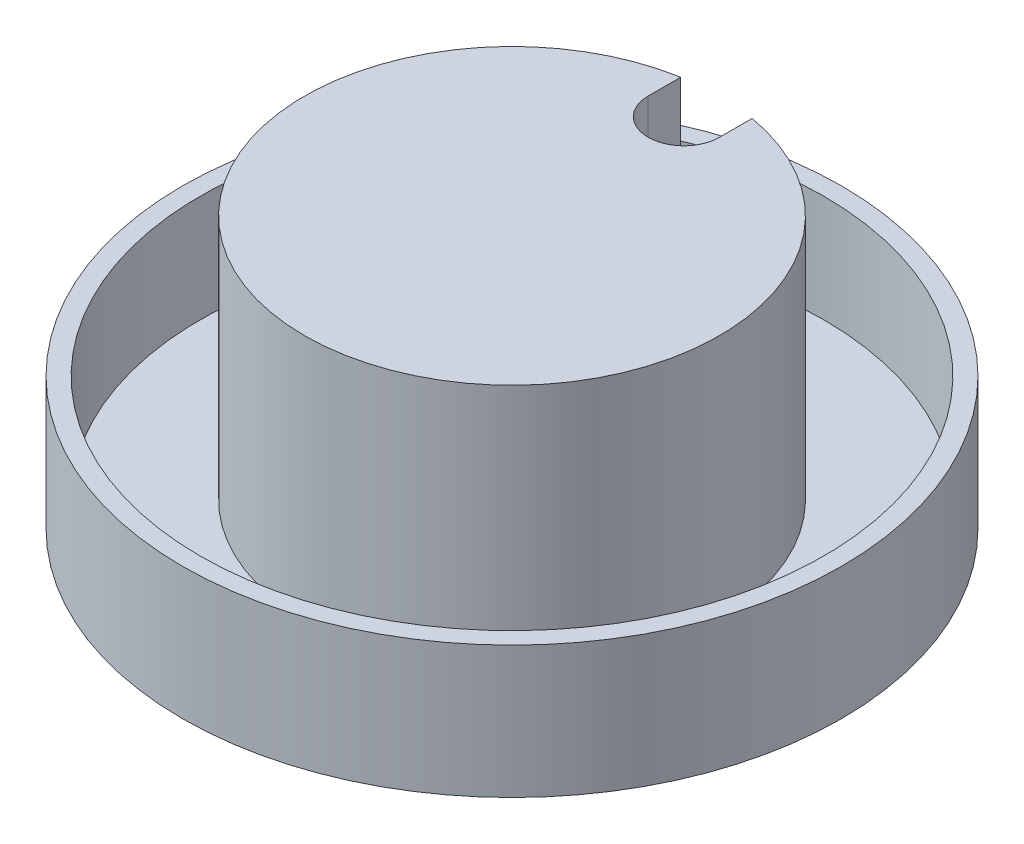
from build123d import *

# Parameters (mm, degrees)
SKETCH1_R            = 19.85
SKETCH1_R_2          = 18.78
BOSS_EXTRUDE3_DEPTH  = 7.95
SKETCH2_R            = 18.78
BOSS_EXTRUDE5_DEPTH  = 1.5
SKETCH4_R            = 12.5
BOSS_EXTRUDE6_DEPTH  = 16.31
SKETCH5_R            = 2.15
SKETCH5_W            = 4.3
SKETCH5_H            = 2.15
CUT_EXTRUDE2_DEPTH   = 16.31
SKETCH6_R            = 11.597360911
CUT_EXTRUDE3_DEPTH   = 14.809999892
SKETCH12_R           = 3.4
SKETCH12_W           = 6.8
SKETCH12_H           = 3.4
BOSS_EXTRUDE8_DEPTH  = 24.969999892
SKETCH5_6_R          = 2.15
SKETCH5_6_W          = 4.3
SKETCH5_6_H          = 2.15
CUT_EXTRUDE5_DEPTH   = 24.969999892
CUT_EXTRUDE6_START   = -14.81
SKETCH14_R           = 15.219310499
SKETCH14_R_2         = 12.5
CUT_EXTRUDE6_DEPTH   = 14.81
SKETCH17_W           = 6.8
SKETCH17_H           = 2.662223843
CUT_EXTRUDE7_DEPTH   = 16.587999892
SKETCH18_R           = 3.4
SKETCH18_R_2         = 2.15
BOSS_EXTRUDE10_DEPTH = 14
SKETCH19_R           = 5.618160511
SKETCH19_R_2         = 3.4
CUT_EXTRUDE8_DEPTH   = 14


with BuildPart() as part:
    # Sketch1 → Boss-Extrude3 (new body)
    with BuildSketch(Plane(origin=(0, 0, 0), x_dir=(1, 0, 0), z_dir=(0, 1, 0))):
        Circle(SKETCH1_R)
        Circle(SKETCH1_R_2, mode=Mode.SUBTRACT)
    extrude(amount=BOSS_EXTRUDE3_DEPTH)

    # Sketch2 → Boss-Extrude5 (add)
    with BuildSketch(Plane.XZ):
        Circle(SKETCH2_R)
    extrude(amount=-BOSS_EXTRUDE5_DEPTH)


with BuildPart() as body_2:
    # Sketch4 → Boss-Extrude6 (new body)
    with BuildSketch(Plane.XZ):
        Circle(SKETCH4_R)
    extrude(amount=-BOSS_EXTRUDE6_DEPTH)


with BuildPart() as cut_extrude2_tool:
    # Sketch5 → Cut-Extrude2 (new body)
    with BuildSketch(Plane(origin=(0, 16.31, 0), x_dir=(1, 0, 0), z_dir=(0, 1, 0))):
        with Locations((0, 10.35)):
            Circle(SKETCH5_R)
        with Locations((0, 11.425)):
            Rectangle(SKETCH5_W, SKETCH5_H)
    extrude(amount=-CUT_EXTRUDE2_DEPTH)


with BuildPart() as part_1:
    add(part.part)

    # Cut-Extrude2: cut by cut_extrude2_tool
    add(cut_extrude2_tool.part, mode=Mode.SUBTRACT)


with BuildPart() as body_2_1:
    add(body_2.part)

    # Cut-Extrude2: cut by cut_extrude2_tool
    add(cut_extrude2_tool.part, mode=Mode.SUBTRACT)


with BuildPart() as cut_extrude3_tool:
    # Sketch6 → Cut-Extrude3 (new body)
    with BuildSketch(Plane.XZ):
        Circle(SKETCH6_R)
    extrude(amount=-CUT_EXTRUDE3_DEPTH)


with BuildPart() as part_2:
    add(part_1.part)

    # Cut-Extrude3: cut by cut_extrude3_tool
    add(cut_extrude3_tool.part, mode=Mode.SUBTRACT)



with BuildPart() as body_2_2:
    add(body_2_1.part)

    # Cut-Extrude3: cut by cut_extrude3_tool
    add(cut_extrude3_tool.part, mode=Mode.SUBTRACT)


with BuildPart() as part_3:
    add(part_2.part)

    add(body_2_2.part)  # Boss-Extrude8 merges body 2
    # Sketch12 → Boss-Extrude8 (add)
    with BuildSketch(Plane(origin=(0, 16.31, 0), x_dir=(1, 0, 0), z_dir=(0, 1, 0))):
        with Locations((0, 10.35)):
            Circle(SKETCH12_R)
        with Locations((0, 12.05)):
            Rectangle(SKETCH12_W, SKETCH12_H)
    extrude(amount=-BOSS_EXTRUDE8_DEPTH)

    # Sketch5_6 → Cut-Extrude5 (cut)
    with BuildSketch(Plane(origin=(0, 16.31, 0), x_dir=(1, 0, 0), z_dir=(0, 1, 0))):
        with Locations((0, 10.35)):
            Circle(SKETCH5_6_R)
        with Locations((0, 11.425)):
            Rectangle(SKETCH5_6_W, SKETCH5_6_H)
    extrude(amount=-CUT_EXTRUDE5_DEPTH, mode=Mode.SUBTRACT)

    # Sketch14 → Cut-Extrude6 (cut)
    with BuildSketch(Plane(origin=(0, 16.31, 0), x_dir=(1, 0, 0), z_dir=(0, 1, 0)).offset(CUT_EXTRUDE6_START)):
        Circle(SKETCH14_R)
        Circle(SKETCH14_R_2, mode=Mode.SUBTRACT)
    extrude(amount=CUT_EXTRUDE6_DEPTH, mode=Mode.SUBTRACT)

    # Sketch17 → Cut-Extrude7 (cut)
    with BuildSketch(Plane.XZ):
        with Locations((0, -12.418888079)):
            Rectangle(SKETCH17_W, SKETCH17_H)
    extrude(amount=CUT_EXTRUDE7_DEPTH, mode=Mode.SUBTRACT)

    # Sketch18 → Boss-Extrude10 (add)
    with BuildSketch(Plane.XZ):
        with Locations((0, -10.35)):
            Circle(SKETCH18_R)
        with Locations((0, -10.35)):
            Circle(SKETCH18_R_2, mode=Mode.SUBTRACT)
    extrude(amount=BOSS_EXTRUDE10_DEPTH)

    # Sketch19 → Cut-Extrude8 (cut)
    with BuildSketch(Plane.XZ):
        with Locations((0, -10.35)):
            Circle(SKETCH19_R)
        with Locations((0, -10.35)):
            Circle(SKETCH19_R_2, mode=Mode.SUBTRACT)
    extrude(amount=CUT_EXTRUDE8_DEPTH, mode=Mode.SUBTRACT)


solid = part_3.part
